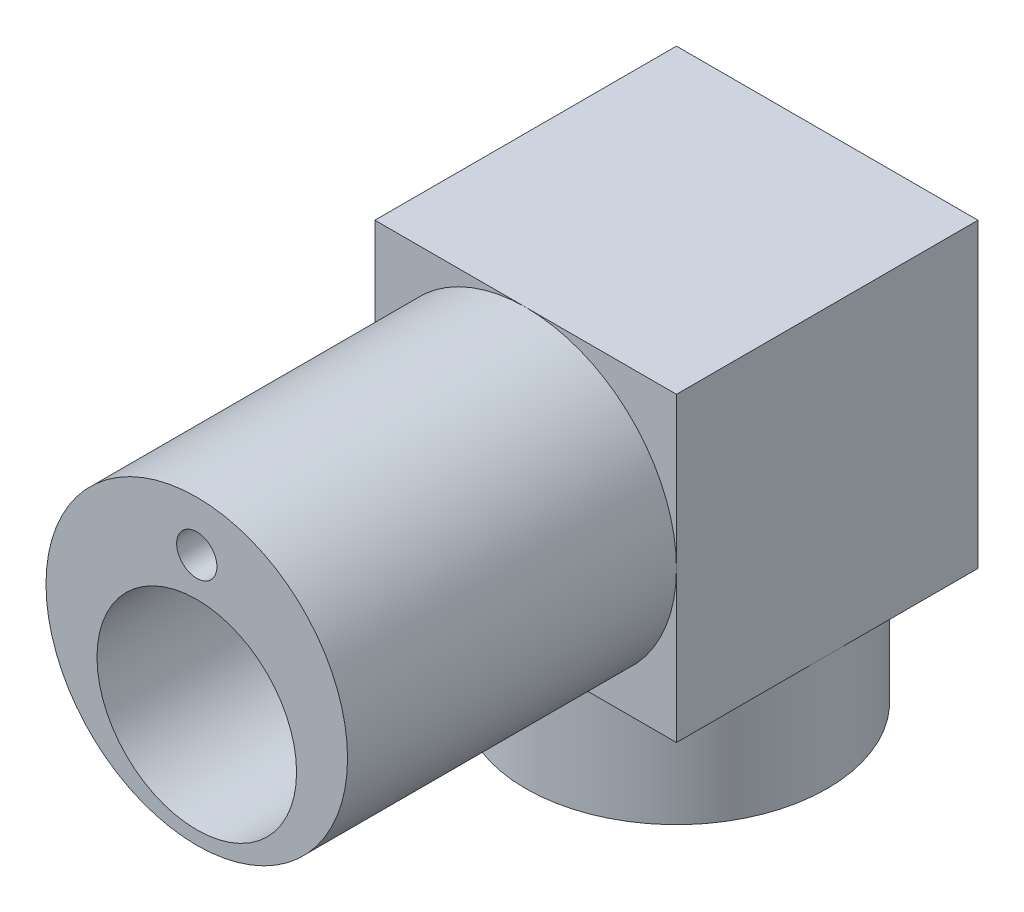
from build123d import *

# Parameters (mm, degrees)
SKETCH1_R           = 28.1
BOSS_EXTRUDE2_DEPTH = 61.3
SKETCH3_R           = 18.6
CUT_EXTRUDE2_DEPTH  = 58.8
SKETCH4_W           = 56.2
SKETCH4_H           = 56.2
BOSS_EXTRUDE3_DEPTH = 56.2
SKETCH5_R           = 16.1
CUT_EXTRUDE4_DEPTH  = 5
SKETCH6_W           = 49.797391422
SKETCH6_H           = 49.779255452
CUT_EXTRUDE5_DEPTH  = 53.7
SKETCH7_R           = 28.1
BOSS_EXTRUDE4_DEPTH = 21.5
CUT_EXTRUDE6_DEPTH  = 21.5
SKETCH9_R           = 3
CUT_EXTRUDE7_DEPTH  = 9.5
SKETCH10_R          = 6.025
CUT_EXTRUDE8_DEPTH  = 6.2
SKETCH18_R          = 3.75
CUT_EXTRUDE9_DEPTH  = 100
SKETCH19_R          = 3.75
CUT_EXTRUDE11_DEPTH = 25


with BuildPart() as part:
    # Sketch1 → Boss-Extrude2 (new body)
    with BuildSketch(Plane.XY):
        Circle(SKETCH1_R)
    extrude(amount=BOSS_EXTRUDE2_DEPTH)

    # Sketch3 → Cut-Extrude2 (cut)
    with BuildSketch(Plane.XY.offset(61.3)):
        with Locations((0, -7)):
            Circle(SKETCH3_R)
    extrude(amount=-CUT_EXTRUDE2_DEPTH, mode=Mode.SUBTRACT)

    # Sketch4 → Boss-Extrude3 (add)
    with BuildSketch(Plane(origin=(0, 0, 0), x_dir=(-1, 0, 0), z_dir=(0, 0, -1))):
        Rectangle(SKETCH4_W, SKETCH4_H)
    extrude(amount=BOSS_EXTRUDE3_DEPTH)

    # Sketch5 → Cut-Extrude4 (cut)
    with BuildSketch(Plane.XY.offset(2.5)):
        with Locations((0, -7)):
            Circle(SKETCH5_R)
    extrude(amount=-CUT_EXTRUDE4_DEPTH, mode=Mode.SUBTRACT)

    # Sketch6 → Cut-Extrude5 (cut)
    with BuildSketch(Plane(origin=(0, 0, -56.2), x_dir=(-1, 0, 0), z_dir=(0, 0, -1))):
        Rectangle(SKETCH6_W, SKETCH6_H)
    extrude(amount=-CUT_EXTRUDE5_DEPTH, mode=Mode.SUBTRACT)

    # Sketch7 → Boss-Extrude4 (add)
    with BuildSketch(Plane(origin=(0, -28.1, 0), x_dir=(-1, 0, 0), z_dir=(0, -1, 0))):
        with Locations(Location((0, 28.1, 0), (0, 0, 90))):
            Circle(SKETCH7_R)
    extrude(amount=BOSS_EXTRUDE4_DEPTH)

    # Sketch8 → Cut-Extrude6 (cut)
    with BuildSketch(Plane(origin=(0, -49.6, 0), x_dir=(-1, 0, 0), z_dir=(0, -1, 0))):
        with BuildLine():
            Line((1.658312395, 25.832078896), (-1.658312395, 25.832078896))
            ThreePointArc((-1.658312395, 25.832078896), (0, 31.332078896), (1.658312395, 25.832078896))
        make_face()
    extrude(amount=-CUT_EXTRUDE6_DEPTH, mode=Mode.SUBTRACT)

    # Sketch9 → Cut-Extrude7 (cut)
    with BuildSketch(Plane(origin=(0, -49.6, 0), x_dir=(-1, 0, 0), z_dir=(0, -1, 0))):
        with Locations(Location((0, 28.332078896, 0), (0, 0, 90))):
            Circle(SKETCH9_R)
    extrude(amount=-CUT_EXTRUDE7_DEPTH, mode=Mode.SUBTRACT)

    # Sketch10 → Cut-Extrude8 (cut)
    with BuildSketch(Plane(origin=(0, -49.6, 0), x_dir=(-1, 0, 0), z_dir=(0, -1, 0))):
        with Locations(Location((0, 28.332078896, 0), (0, 0, 90))):
            Circle(SKETCH10_R)
    extrude(amount=-CUT_EXTRUDE8_DEPTH, mode=Mode.SUBTRACT)

    # Cut-Sweep4: sweep along a path in Sketch15
    with BuildLine(Plane(origin=(0, -49.6, 0), x_dir=(-1, 0, 0), z_dir=(0, -1, 0))) as cut_sweep4_path:
        ThreePointArc((15, 28.332078896), (0, 43.332078896), (-15, 28.332078896))
    # 3DSketch2 → Cut-Sweep4 (sweep, cut)
    with BuildSketch(Plane(origin=(-15, -49.6, -28.332078896), x_dir=(-0.24561664909913958, 0.9693670417779378, 0), z_dir=(0, 0, 1))):
        Polygon((0, 0), (1.842124868, 7.270252813), (30.535389305, 0), (28.693264437, -7.270252813), align=None)
    sweep(path=cut_sweep4_path.line, mode=Mode.SUBTRACT)

    # Sketch18 → Cut-Extrude9 (cut)
    with BuildSketch(Plane.XY.offset(61.3)):
        with Locations((0, 18.75)):
            Circle(SKETCH18_R)
    extrude(amount=-CUT_EXTRUDE9_DEPTH, mode=Mode.SUBTRACT)

    # Sketch19 → Cut-Extrude11 (cut)
    with BuildSketch(Plane(origin=(0, -49.6, 0), x_dir=(-1, 0, 0), z_dir=(0, -1, 0))):
        with Locations((-18.75, 28.332078896)):
            Circle(SKETCH19_R)
        with Locations((18.75, 28.332078896)):
            Circle(SKETCH19_R)
    extrude(amount=-CUT_EXTRUDE11_DEPTH, mode=Mode.SUBTRACT)


solid = part.part
